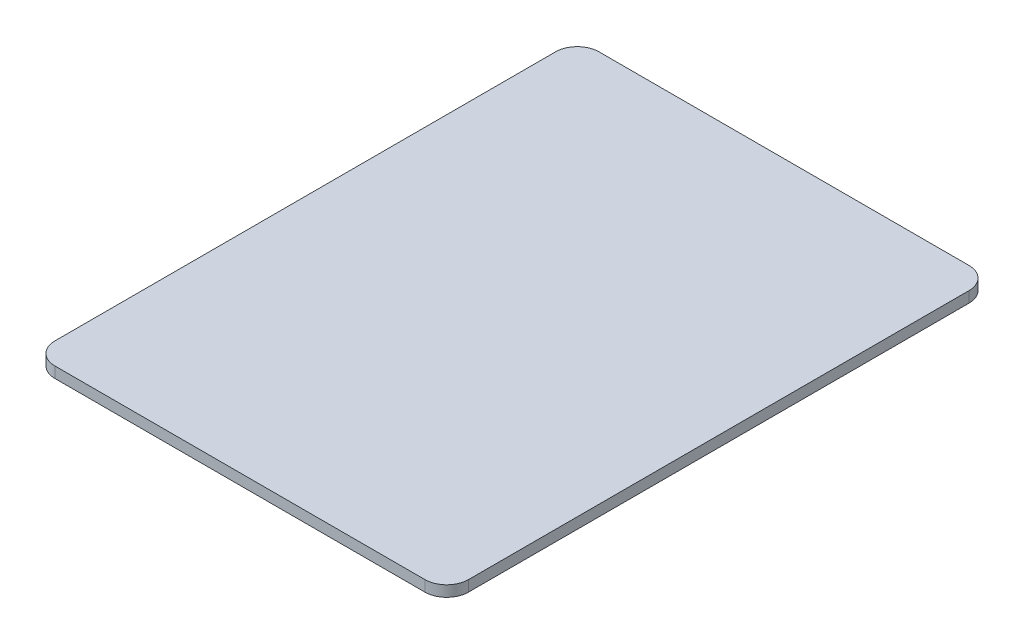
from build123d import *

# Parameters (mm, degrees)
CROQUIS1_W              = 190
CROQUIS1_H              = 250
SALIENTE_EXTRUIR1_DEPTH = 5
REDONDEO1_R             = 10
CROQUIS2_W              = 150
CROQUIS2_H              = 230
SALIENTE_EXTRUIR2_DEPTH = 10


with BuildPart() as part:
    # Croquis1 → Saliente-Extruir1 (new body)
    with BuildSketch(Plane(origin=(0, 0, 0), x_dir=(1, 0, 0), z_dir=(0, 1, 0))):
        with Locations((95, 125)):
            Rectangle(CROQUIS1_W, CROQUIS1_H)
    extrude(amount=SALIENTE_EXTRUIR1_DEPTH)

    # Redondeo1
    redondeo1_edges = [part.edges().sort_by_distance(p)[0] for p in [
        (0, 2.5, -250),
        (190, 2.5, -250),
        (190, 2.5, 0),
        (0, 2.5, 0),
    ]]
    fillet(redondeo1_edges, radius=REDONDEO1_R)

    # Croquis2 → Saliente-Extruir2 (add)
    with BuildSketch(Plane.XZ):
        with Locations((95, -125)):
            Rectangle(CROQUIS2_W, CROQUIS2_H)
    extrude(amount=SALIENTE_EXTRUIR2_DEPTH)


solid = part.part
